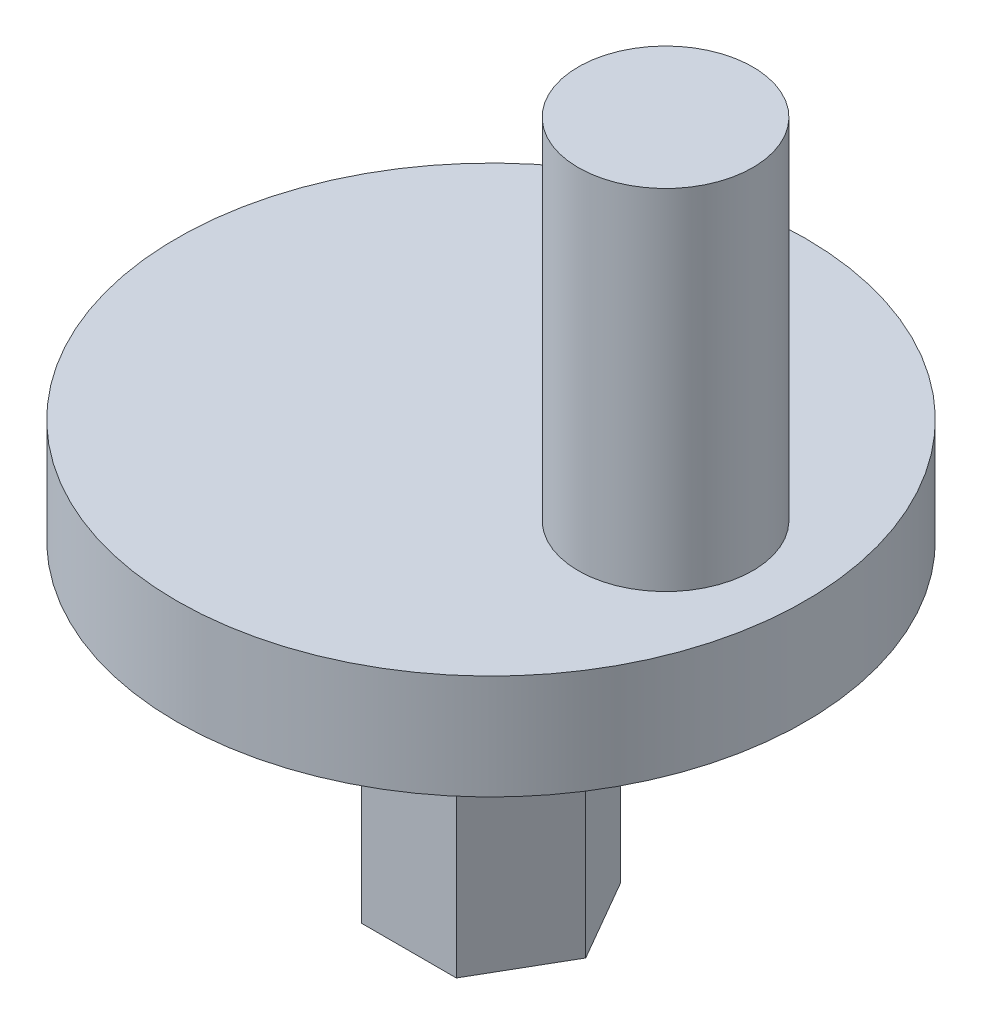
from build123d import *

# Parameters (mm, degrees)
SKETCH1_R           = 9
BOSS_EXTRUDE1_DEPTH = 3
SKETCH2_R           = 2.5
BOSS_EXTRUDE2_DEPTH = 10
BOSS_EXTRUDE3_DEPTH = 9


with BuildPart() as part:
    # Sketch1 → Boss-Extrude1 (new body)
    with BuildSketch(Plane(origin=(0, 0, 0), x_dir=(1, 0, 0), z_dir=(0, 1, 0))):
        Circle(SKETCH1_R)
    extrude(amount=BOSS_EXTRUDE1_DEPTH)

    # Sketch2 → Boss-Extrude2 (add)
    with BuildSketch(Plane(origin=(0, 3, 0), x_dir=(1, 0, 0), z_dir=(0, 1, 0))):
        with Locations((5, 0)):
            Circle(SKETCH2_R)
    extrude(amount=BOSS_EXTRUDE2_DEPTH)

    # Sketch3 → Boss-Extrude3 (add)
    with BuildSketch(Plane.XZ):
        Polygon((2.713546265, 0), (1.356773133, 2.35), (-1.356773133, 2.35), (-2.713546265, 0), (-1.356773133, -2.35), (1.356773133, -2.35), align=None)
    extrude(amount=BOSS_EXTRUDE3_DEPTH)


solid = part.part
